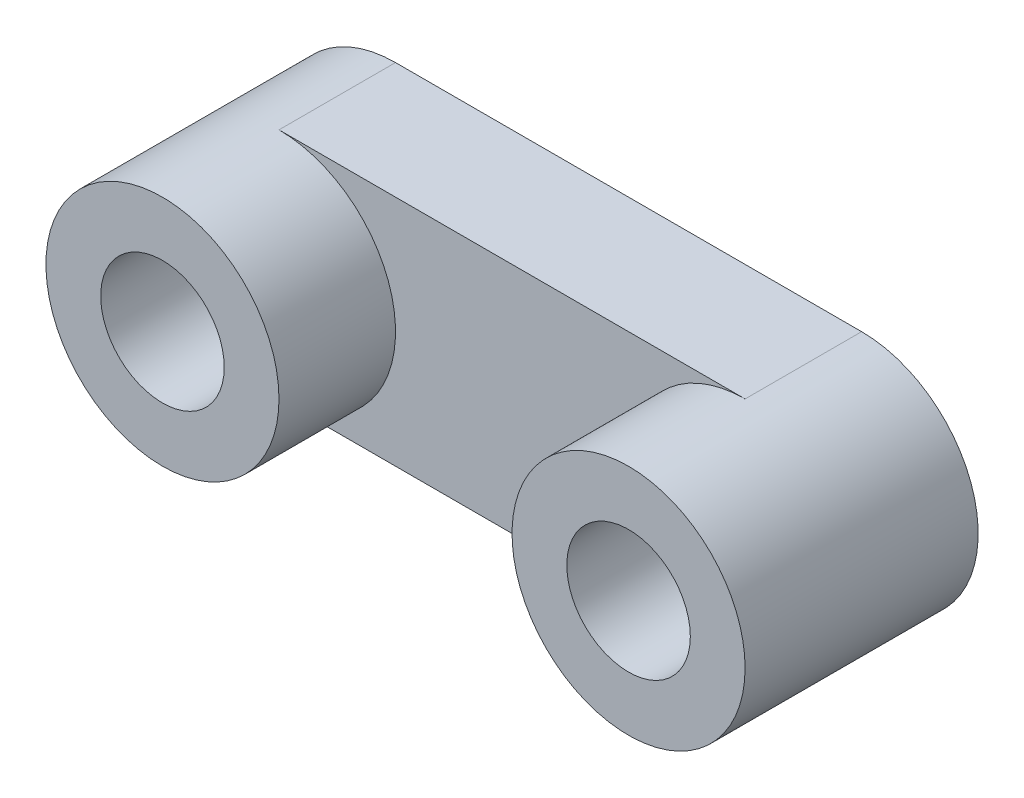
from build123d import *

# Parameters (mm, degrees)
ESTRUSIONE_ESTRUSIONE1_DEPTH = 5
SCHIZZO2_R                   = 5
SCHIZZO2_R_2                 = 2.65
ESTRUSIONE_ESTRUSIONE2_DEPTH = 5
SCHIZZO3_R                   = 1.75
TAGLIO_ESTRUSIONE1_DEPTH     = 19.539256374


with BuildPart() as part:
    # Schizzo1 → Estrusione-Estrusione1 (new body)
    with BuildSketch(Plane.XY):
        with BuildLine():
            Line((-7.862204724, 5), (12.137795276, 5))
            ThreePointArc((12.137795276, 5), (17.137795276, 0), (12.137795276, -5))
            Line((12.137795276, -5), (-7.862204724, -5))
            ThreePointArc((-7.862204724, -5), (-12.862204724, 0), (-7.862204724, 5))
        make_face()
    extrude(amount=ESTRUSIONE_ESTRUSIONE1_DEPTH)

    # Schizzo2 → Estrusione-Estrusione2 (add)
    # profile 1 of 2: a face of its own
    with BuildSketch(Plane.XY.offset(5)):
        with Locations((-7.862204724, 0)):
            Circle(SCHIZZO2_R)
        with Locations((-7.862204724, 0)):
            Circle(SCHIZZO2_R_2, mode=Mode.SUBTRACT)
    # profile 2 of 2: a face of its own
    with BuildSketch(Plane.XY.offset(5)):
        with Locations((12.137795276, 0)):
            Circle(SCHIZZO2_R)
        with Locations((12.137795276, 0)):
            Circle(SCHIZZO2_R_2, mode=Mode.SUBTRACT)
    extrude(amount=ESTRUSIONE_ESTRUSIONE2_DEPTH)

    # Schizzo3 → Taglio-Estrusione1 (cut, through all)
    with BuildSketch(Plane.XY.offset(5)):
        with Locations((-7.862204724, 0)):
            Circle(SCHIZZO3_R)
        with Locations((12.137795276, 0)):
            Circle(SCHIZZO3_R)
    extrude(amount=-TAGLIO_ESTRUSIONE1_DEPTH, mode=Mode.SUBTRACT)


solid = part.part
